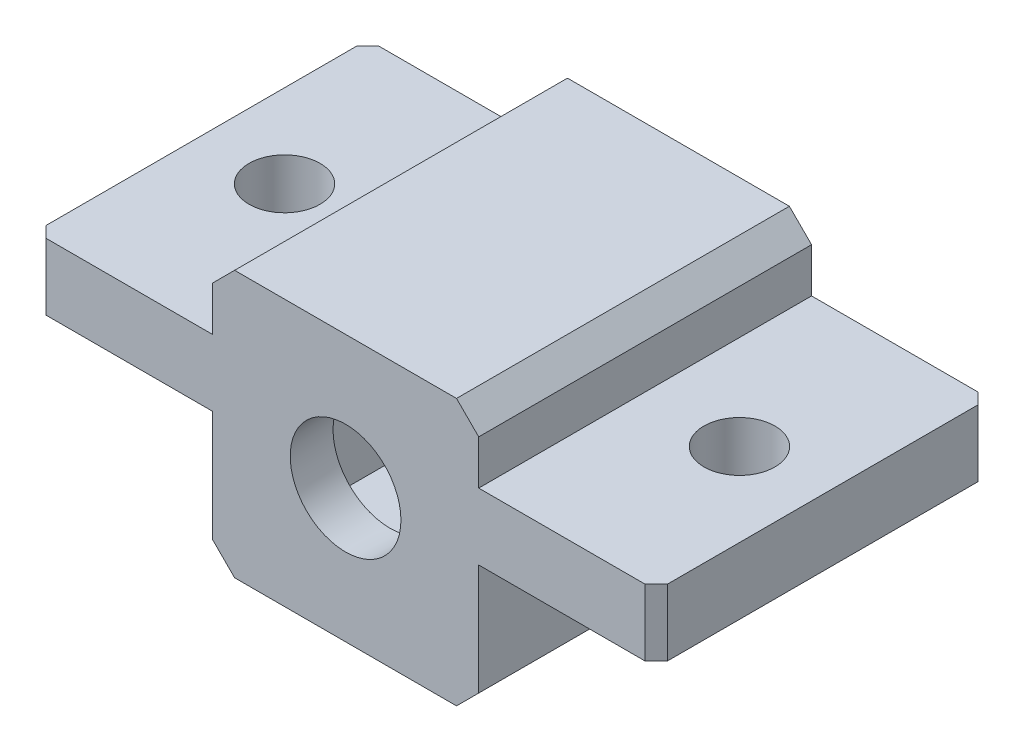
from build123d import *

# Parameters (mm, degrees)
ESQUISSE1_W                  = 12
ESQUISSE1_H                  = 12
BOSS_EXTRU_1_DEPTH           = 15
ENL_V_START                  = -3
ESQUISSE2_R                  = 2.6
ENL_V_MAT_EXTRU_1_DEPTH      = 51.706317156
ENL_V_MAT_EXTRU_1_TAPER      = 2
ESQUISSE3_W                  = 8
ESQUISSE3_H                  = 8
ENL_V_MAT_EXTRU_2_DEPTH      = 13
CHANFREIN1_SIZE              = 1
ESQUISSE4_W                  = 15
ESQUISSE4_H                  = 3
BOSS_EXTRU_2_DEPTH           = 8
ESQUISSE5_R                  = 1.6
ENL_V_MAT_EXTRU_3_DEPTH      = 46.588944696
CHANFREIN2_SIZE              = 0.5
CHANFREIN2_OF_SYM_TRIE1_SIZE = 0.5


with BuildPart() as part:
    # Esquisse1 → Boss.-Extru.1 (new body)
    with BuildSketch(Plane.XY):
        with Locations((-28.630410255, 23.182655502)):
            Rectangle(ESQUISSE1_W, ESQUISSE1_H)
    extrude(amount=BOSS_EXTRU_1_DEPTH)

    # Esquisse2 → Enlèv. mat.-Extru.1 (cut, through all)
    with BuildSketch(Plane.XY.offset(15).offset(ENL_V_START)):
        with Locations((-28.630410255, 23.182655502)):
            Circle(ESQUISSE2_R)
    extrude(amount=ENL_V_MAT_EXTRU_1_DEPTH, taper=ENL_V_MAT_EXTRU_1_TAPER, mode=Mode.SUBTRACT)

    # Esquisse3 → Enlèv. mat.-Extru.2 (cut)
    with BuildSketch(Plane(origin=(0, 0, 0), x_dir=(-1, 0, 0), z_dir=(0, 0, -1))):
        with Locations((28.630410255, 23.182655502)):
            Rectangle(ESQUISSE3_W, ESQUISSE3_H)
    extrude(amount=-ENL_V_MAT_EXTRU_2_DEPTH, mode=Mode.SUBTRACT)

    # Chanfrein1
    chanfrein1_edges = [part.edges().sort_by_distance(p)[0] for p in [
        (-34.630410255, 29.182655502, 7.5),
        (-22.630410255, 29.182655502, 7.5),
        (-22.630410255, 17.182655502, 7.5),
        (-34.630410255, 17.182655502, 7.5),
    ]]
    chamfer(chanfrein1_edges, length=CHANFREIN1_SIZE)

    # Esquisse4 → Boss.-Extru.2 (add)
    with BuildSketch(Plane.ZY.offset(34.630410255)):
        with Locations((7.5, 24.682655502)):
            Rectangle(ESQUISSE4_W, ESQUISSE4_H)
    boss_extru_2 = extrude(amount=BOSS_EXTRU_2_DEPTH)

    # Esquisse5 → Enlèv. mat.-Extru.3 (cut, through all)
    with BuildSketch(Plane.XZ.offset(-23.182655502)):
        with Locations((-38.880410255, 7.5)):
            Circle(ESQUISSE5_R)
    enl_v_mat_extru_3 = extrude(amount=-ENL_V_MAT_EXTRU_3_DEPTH, mode=Mode.SUBTRACT)

    # Chanfrein2
    chanfrein2_edges = [part.edges().sort_by_distance(p)[0] for p in [
        (-42.630410255, 24.682655502, 15),
        (-42.630410255, 24.682655502, 0),
    ]]
    chamfer(chanfrein2_edges, length=CHANFREIN2_SIZE)

    # Symétrie1: Boss.-Extru.2, Enlèv. mat.-Extru.3 across plane
    add(boss_extru_2.mirror(Plane.ZY.offset(28.630410255)))
    add(enl_v_mat_extru_3.mirror(Plane.ZY.offset(28.630410255)), mode=Mode.SUBTRACT)

    # Chanfrein2 of Symétrie1
    chanfrein2_of_sym_trie1_edges = [part.edges().sort_by_distance(p)[0] for p in [
        (-14.630410255, 24.682655502, 15),
        (-14.630410255, 24.682655502, 0),
    ]]
    chamfer(chanfrein2_of_sym_trie1_edges, length=CHANFREIN2_OF_SYM_TRIE1_SIZE)


solid = part.part
